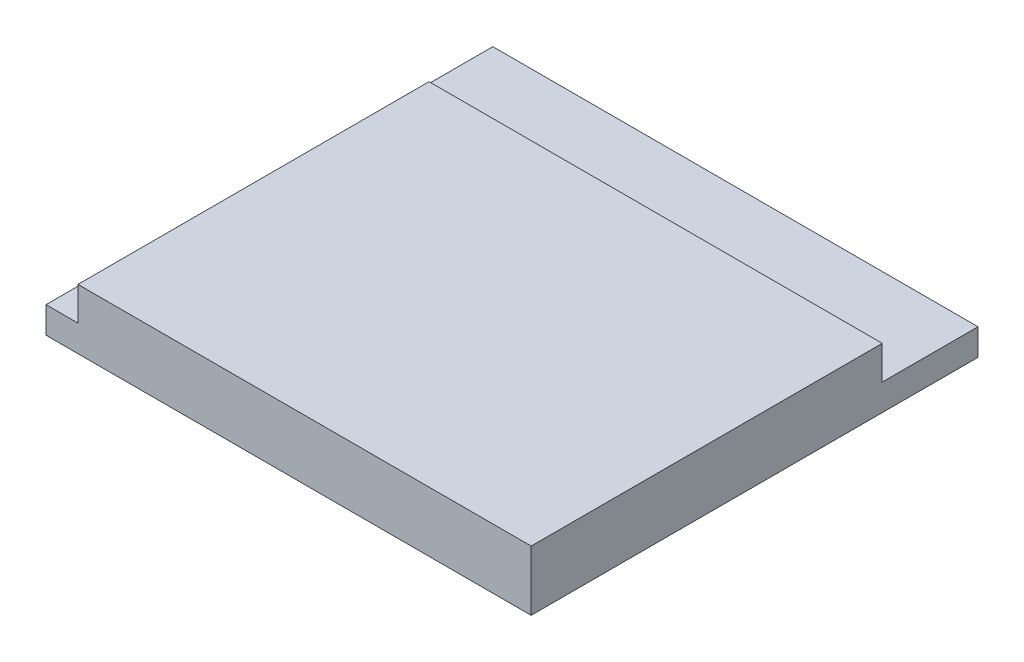
from build123d import *

# Parameters (mm, degrees)
SKETCH1_W           = 15.2
SKETCH1_H           = 14
BOSS_EXTRUDE1_DEPTH = 0.83
SKETCH2_W           = 14.2
SKETCH2_H           = 11
BOSS_EXTRUDE2_DEPTH = 1.05


with BuildPart() as part:
    # Sketch1 → Boss-Extrude1 (new body)
    with BuildSketch(Plane(origin=(0, 0, 0), x_dir=(1, 0, 0), z_dir=(0, 1, 0))):
        Rectangle(SKETCH1_W, SKETCH1_H)
    extrude(amount=BOSS_EXTRUDE1_DEPTH)

    # Sketch2 → Boss-Extrude2 (add)
    with BuildSketch(Plane(origin=(0, 0.83, 0), x_dir=(1, 0, 0), z_dir=(0, 1, 0))):
        with Locations((0.5, -1.5)):
            Rectangle(SKETCH2_W, SKETCH2_H)
    extrude(amount=BOSS_EXTRUDE2_DEPTH)


solid = part.part
